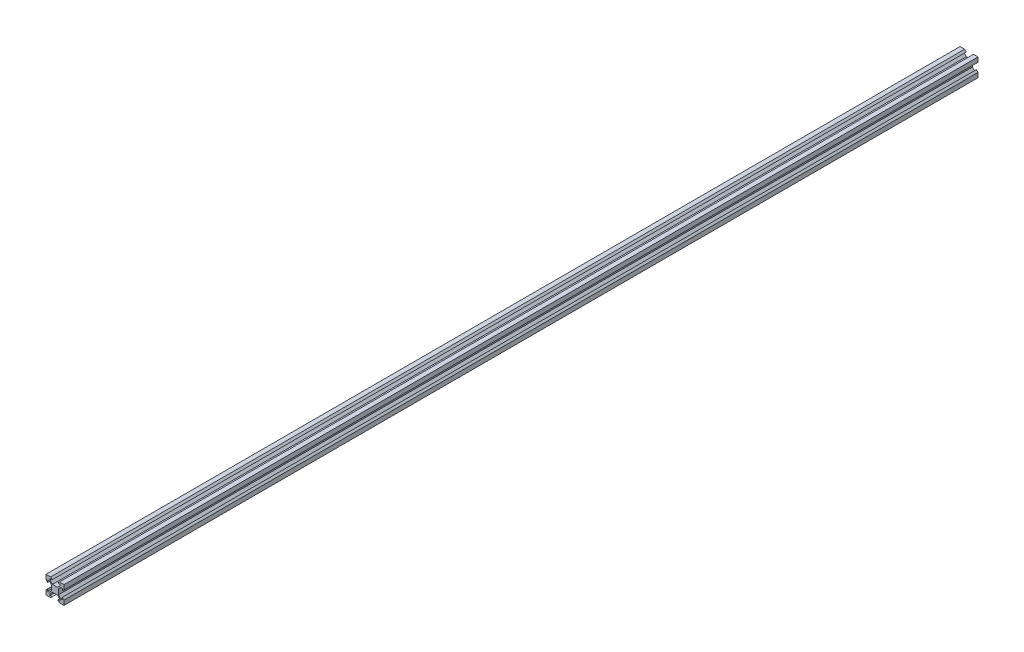
from build123d import *

# Parameters (mm, degrees)
SKETCH1_W           = 20
SKETCH1_H           = 20
BOSS_EXTRUDE1_DEPTH = 1014.98
CUT_EXTRUDE1_DEPTH  = 1015.98


with BuildPart() as part:
    # Sketch1 → Boss-Extrude1 (new body)
    with BuildSketch(Plane.XY):
        with Locations((10, 10)):
            Rectangle(SKETCH1_W, SKETCH1_H)
    extrude(amount=BOSS_EXTRUDE1_DEPTH)

    # Sketch2 → Cut-Extrude1 (cut, through all)
    with BuildSketch(Plane.XY.offset(1014.98)):
        Polygon((4.5, 18.18), (6.94, 18.18), (5.12, 20), (14.88, 20), (13.06, 18.18), (15.5, 18.18), (15.5, 16.475807358), (12.834192642, 13.81), (7.165807358, 13.81), (4.5, 16.475807358), align=None)
        Polygon((14.88, 0), (13.06, 1.82), (15.5, 1.82), (15.5, 3.524192642), (12.834192642, 6.19), (7.165807358, 6.19), (4.5, 3.524192642), (4.5, 1.82), (6.94, 1.82), (5.12, 0), align=None)
        Polygon((1.82, 4.5), (1.82, 6.94), (0, 5.12), (0, 14.88), (1.82, 13.06), (1.82, 15.5), (3.524192642, 15.5), (6.19, 12.834192642), (6.19, 7.165807358), (3.524192642, 4.5), align=None)
        Polygon((20, 14.88), (18.18, 13.06), (18.18, 15.5), (16.475807358, 15.5), (13.81, 12.834192642), (13.81, 7.165807358), (16.475807358, 4.5), (18.18, 4.5), (18.18, 6.94), (20, 5.12), align=None)
    extrude(amount=-CUT_EXTRUDE1_DEPTH, mode=Mode.SUBTRACT)


solid = part.part
